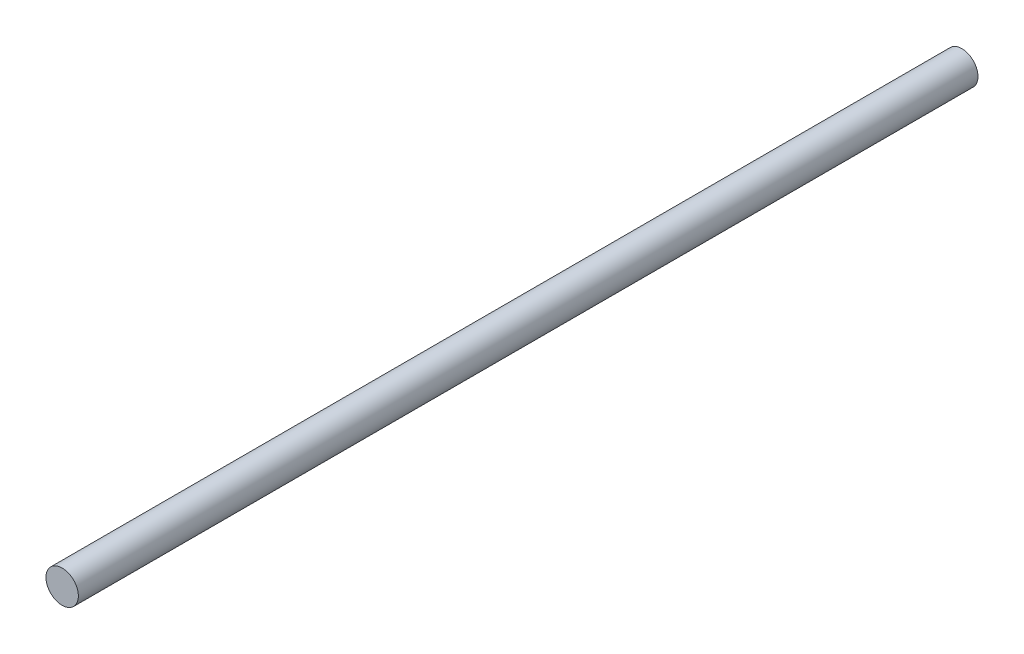
from build123d import *

# Parameters (mm, degrees)
SKETCH1_R           = 9
BOSS_EXTRUDE1_DEPTH = 500


with BuildPart() as part:
    # Sketch1 → Boss-Extrude1 (new body)
    with BuildSketch(Plane.XY):
        Circle(SKETCH1_R)
    extrude(amount=BOSS_EXTRUDE1_DEPTH)


solid = part.part
